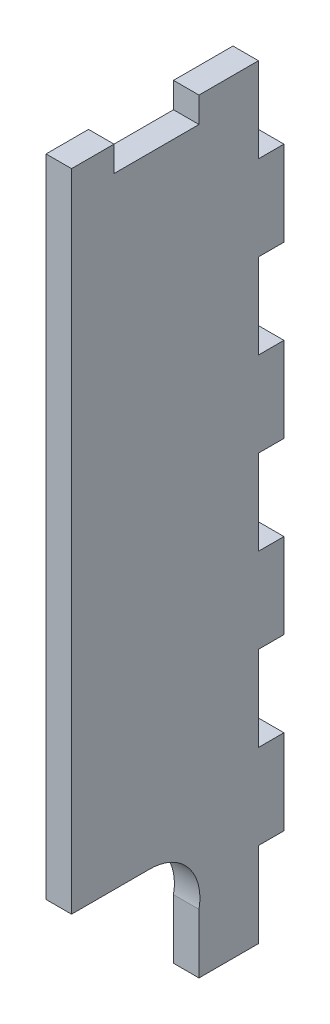
from build123d import *

# Parameters (mm, degrees)
BOSS_EXTRUDE1_DEPTH = 3


with BuildPart() as part:
    # Sketch1 → Boss-Extrude1 (new body)
    with BuildSketch(Plane(origin=(0, 0, 0), x_dir=(0, 0, -1), z_dir=(1, 0, 0))):
        with BuildLine():
            Line((24.704010852, 12.720489708), (33.704010852, 12.720489708))
            ThreePointArc((33.704010852, 12.720489708), (38.387131684, 10.663164706), (39.704010852, 5.720489708))
            Line((39.704010852, 5.720489708), (39.704010852, -1.279510292))
            Line((39.704010852, -1.279510292), (46.704010852, -1.279510292))
            Line((46.704010852, -1.279510292), (46.704010852, 8.720489708))
            Line((46.704010852, 8.720489708), (49.704010852, 8.720489708))
            Line((49.704010852, 8.720489708), (49.704010852, 18.720489708))
            Line((49.704010852, 18.720489708), (46.704010852, 18.720489708))
            Line((46.704010852, 18.720489708), (46.704010852, 28.720489708))
            Line((46.704010852, 28.720489708), (49.704010852, 28.720489708))
            Line((49.704010852, 28.720489708), (49.704010852, 38.720489708))
            Line((49.704010852, 38.720489708), (46.704010852, 38.720489708))
            Line((46.704010852, 38.720489708), (46.704010852, 48.720489708))
            Line((46.704010852, 48.720489708), (49.704010852, 48.720489708))
            Line((49.704010852, 48.720489708), (49.704010852, 58.720489708))
            Line((49.704010852, 58.720489708), (46.704010852, 58.720489708))
            Line((46.704010852, 58.720489708), (46.704010852, 68.720489708))
            Line((46.704010852, 68.720489708), (49.704010852, 68.720489708))
            Line((49.704010852, 68.720489708), (49.704010852, 78.720489708))
            Line((49.704010852, 78.720489708), (46.704010852, 78.720489708))
            Line((46.704010852, 78.720489708), (46.704010852, 88.720489708))
            Line((46.704010852, 88.720489708), (39.704010852, 88.720489708))
            Line((39.704010852, 88.720489708), (39.704010852, 85.720489708))
            Line((39.704010852, 85.720489708), (29.704010852, 85.720489708))
            Line((29.704010852, 85.720489708), (29.704010852, 88.720489708))
            Line((29.704010852, 88.720489708), (24.704010852, 88.720489708))
            Line((24.704010852, 88.720489708), (24.704010852, 12.720489708))
        make_face()
    extrude(amount=BOSS_EXTRUDE1_DEPTH)


solid = part.part
